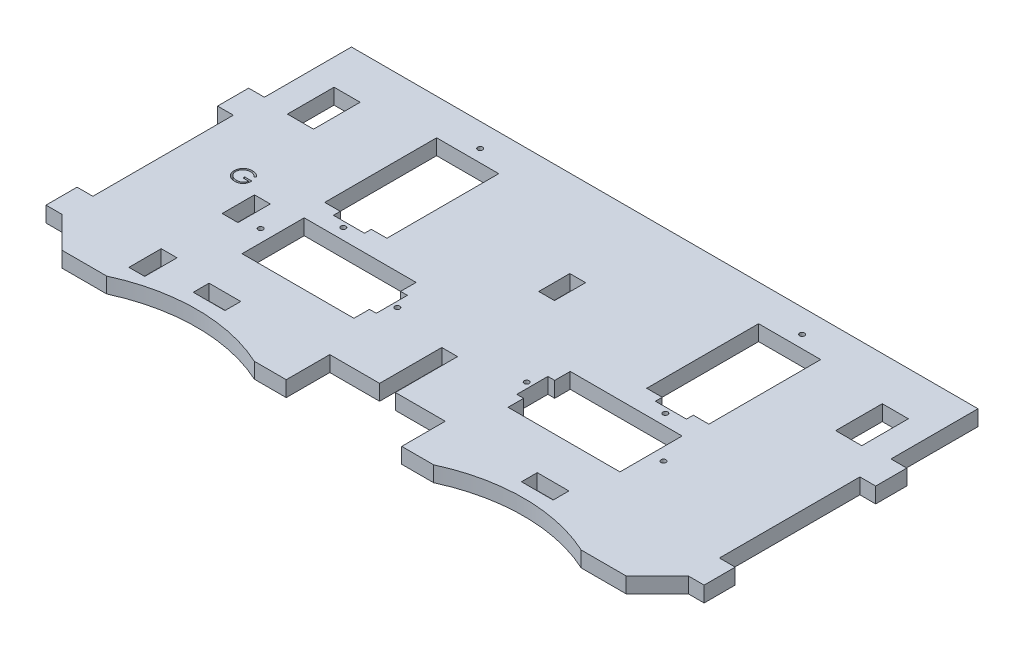
from build123d import *

# Parameters (mm, degrees)
SKETCH1_W                    = 128.016
SKETCH1_H                    = 60.452
MAIN_BODY_DEPTH              = 3.175
SKETCH2_W                    = 6.477
SKETCH2_H                    = 3.2258
CUT_FOR_EYE_CENTER_TAB_DEPTH = 71.857009286
SKETCH3_W                    = 3.2258
SKETCH3_H                    = 6.35
TABS_DEPTH                   = 3.175
SKETCH4_R                    = 0.508
CUT_FOR_MOTORS_DEPTH         = 74.783979043
SKETCH5_W                    = 3.2258
SKETCH5_H                    = 21.59
SKETCH5_H_2                  = 6.35
CUT_EXTRUDE2_DEPTH           = 74.783979043
CUT_EXTRUDE7_DEPTH           = 74.783979043
SKETCH10_W                   = 5.334
SKETCH10_H                   = 9.525
CUT_FOR_SERVO_WIRES_DEPTH    = 74.783979043
SKETCH12_W                   = 10.184723166
SKETCH12_H                   = 8.89
CUT_EXTRUDE9_DEPTH           = 74.783979043
SKETCH13_W                   = 128.016
SKETCH13_H                   = 5.08
BOSS_EXTRUDE1_DEPTH          = 3.175
SKETCH14_R                   = 0.508
CUT_EXTRUDE10_DEPTH          = 77.00643475
SKETCH15_W                   = 3.2258
SKETCH15_H                   = 6.604
CUT_FOR_GEAR_TABS_DEPTH      = 77.00643475
CUT_EXTRUDE11_DEPTH          = 77.00643475
CUT_EXTRUDE12_DEPTH          = 77.006434889


with BuildPart() as part:
    # Sketch1 → main body (new body)
    with BuildSketch(Plane(origin=(0, 0, 0), x_dir=(1, 0, 0), z_dir=(0, 1, 0))):
        Rectangle(SKETCH1_W, SKETCH1_H)
    extrude(amount=MAIN_BODY_DEPTH)

    # Sketch2 → cut for eye center tab (cut, through all)
    with BuildSketch(Plane(origin=(0, 3.175, 0), x_dir=(1, 0, 0), z_dir=(0, 1, 0))):
        with Locations((-33.528, -22.6441)):
            Rectangle(SKETCH2_W, SKETCH2_H)
    cut_for_eye_center_tab = extrude(amount=-CUT_FOR_EYE_CENTER_TAB_DEPTH, mode=Mode.SUBTRACT)

    # Sketch3 → tabs (add)
    with BuildSketch(Plane(origin=(0, 3.175, 0), x_dir=(1, 0, 0), z_dir=(0, 1, 0))):
        with Locations((-65.6209, -20.701)):
            Rectangle(SKETCH3_W, SKETCH3_H)
        with Locations((-65.6209, 14.351)):
            Rectangle(SKETCH3_W, SKETCH3_H)
    tabs = extrude(amount=-TABS_DEPTH)

    # Sketch4 → cut for motors (cut, through all)
    with BuildSketch(Plane(origin=(0, 3.175, 0), x_dir=(1, 0, 0), z_dir=(0, 1, 0))):
        with Locations((-32.893, 2.54)):
            Circle(SKETCH4_R)
        with Locations((-32.893, 30.48)):
            Circle(SKETCH4_R)
        with Locations((-13.208, -6.096)):
            Circle(SKETCH4_R)
        with Locations((-41.148, -6.096)):
            Circle(SKETCH4_R)
        Polygon((-26.543, 27.94), (-39.243, 27.94), (-39.243, 5.08), (-36.068, 5.08), (-36.068, 3.683), (-29.718, 3.683), (-29.718, 5.08), (-26.543, 5.08), align=None)
        Polygon((-38.608, 0.254), (-38.608, -12.446), (-15.748, -12.446), (-15.748, -9.271), (-14.351, -9.271), (-14.351, -2.921), (-15.748, -2.921), (-15.748, 0.254), align=None)
    cut_for_motors = extrude(amount=-CUT_FOR_MOTORS_DEPTH, mode=Mode.SUBTRACT)

    # Mirror of cut for motors: cut for motors across plane
    add(cut_for_motors.mirror(Plane(origin=(0, 0, 0), x_dir=(0, 0, 1), z_dir=(1, 0, 0))), mode=Mode.SUBTRACT)

    # mirror or tabs: tabs across plane
    add(tabs.mirror(Plane(origin=(0, 0, 0), x_dir=(0, 0, 1), z_dir=(1, 0, 0))))

    # mirror of eye center tab: cut for eye center tab across plane
    add(cut_for_eye_center_tab.mirror(Plane(origin=(0, 0, 0), x_dir=(0, 0, 1), z_dir=(1, 0, 0))), mode=Mode.SUBTRACT)

    # Sketch5 → Cut-Extrude2 (cut, through all)
    with BuildSketch(Plane(origin=(0, 3.175, 0), x_dir=(1, 0, 0), z_dir=(0, 1, 0))):
        with Locations((0, -19.431)):
            Rectangle(SKETCH5_W, SKETCH5_H)
        with Locations((0, 14.351)):
            Rectangle(SKETCH5_W, SKETCH5_H_2)
    extrude(amount=-CUT_EXTRUDE2_DEPTH, mode=Mode.SUBTRACT)

    # Sketch9 → Cut-Extrude7 (cut, through all)
    with BuildSketch(Plane(origin=(0, 3.175, 0), x_dir=(1, 0, 0), z_dir=(0, 1, 0))):
        Polygon((-64.008, -23.876), (-64.008, -30.226), (-57.658, -30.226), align=None)
        Polygon((64.008, -30.226), (64.008, -23.876), (57.658, -30.226), align=None)
    extrude(amount=-CUT_EXTRUDE7_DEPTH, mode=Mode.SUBTRACT)

    # Sketch10 → cut for servo wires (cut, through all)
    with BuildSketch(Plane(origin=(0, 3.175, 0), x_dir=(1, 0, 0), z_dir=(0, 1, 0))):
        with Locations((-56.007, 21.6535)):
            Rectangle(SKETCH10_W, SKETCH10_H)
    cut_for_servo_wires = extrude(amount=-CUT_FOR_SERVO_WIRES_DEPTH, mode=Mode.SUBTRACT)

    # Mirror1: cut for servo wires across plane
    add(cut_for_servo_wires.mirror(Plane(origin=(0, 0, 0), x_dir=(0, 0, 1), z_dir=(1, 0, 0))), mode=Mode.SUBTRACT)

    # Sketch12 → Cut-Extrude9 (cut, through all)
    with BuildSketch(Plane(origin=(0, 3.175, 0), x_dir=(1, 0, 0), z_dir=(0, 1, 0))):
        with Locations((-6.705261583, -25.781)):
            Rectangle(SKETCH12_W, SKETCH12_H)
    cut_extrude9 = extrude(amount=-CUT_EXTRUDE9_DEPTH, mode=Mode.SUBTRACT)

    # Mirror2: Cut-Extrude9 across plane
    add(cut_extrude9.mirror(Plane(origin=(0, 0, 0), x_dir=(0, 0, 1), z_dir=(1, 0, 0))), mode=Mode.SUBTRACT)

    # Sketch13 → Boss-Extrude1 (add)
    with BuildSketch(Plane(origin=(0, 3.175, 0), x_dir=(1, 0, 0), z_dir=(0, 1, 0))):
        with Locations((0, 32.766)):
            Rectangle(SKETCH13_W, SKETCH13_H)
    extrude(amount=-BOSS_EXTRUDE1_DEPTH)

    # Sketch14 → Cut-Extrude10 (cut, through all)
    with BuildSketch(Plane(origin=(0, 3.175, 0), x_dir=(1, 0, 0), z_dir=(0, 1, 0))):
        with Locations((-32.893, 30.48)):
            Circle(SKETCH14_R)
    cut_extrude10 = extrude(amount=-CUT_EXTRUDE10_DEPTH, mode=Mode.SUBTRACT)

    # Mirror3: Cut-Extrude10 across plane
    add(cut_extrude10.mirror(Plane(origin=(0, 0, 0), x_dir=(0, 0, 1), z_dir=(1, 0, 0))), mode=Mode.SUBTRACT)

    # Sketch15 → cut for gear tabs (cut, through all)
    with BuildSketch(Plane(origin=(0, 3.175, 0), x_dir=(1, 0, 0), z_dir=(0, 1, 0))):
        with Locations((-46.1391, -4.064)):
            Rectangle(SKETCH15_W, SKETCH15_H)
        with Locations((-46.1391, -23.114)):
            Rectangle(SKETCH15_W, SKETCH15_H)
    extrude(amount=-CUT_FOR_GEAR_TABS_DEPTH, mode=Mode.SUBTRACT)

    # Sketch16 → Cut-Extrude11 (cut, through all)
    with BuildSketch(Plane(origin=(0, 3.175, 0), x_dir=(1, 0, 0), z_dir=(0, 1, 0))):
        with BuildLine():
            Line((-50.659804407, 2.607078125), (-50.929035177, 2.351869792))
            add(Edge.make_bspline(
                [(-50.929035177, 2.351869792), (-50.977754065, 2.397700655), (-51.074030111, 2.488269518), (-51.230990354, 2.605780513), (-51.394753988, 2.706446613), (-51.564466485, 2.78835285), (-51.735925039, 2.85370561), (-51.906853815, 2.90023375), (-52.075499516, 2.929906288), (-52.187666735, 2.933454657), (-52.24293742, 2.935203125)],
                knots=[0, 0, 0, 0, 1.08915593, 2.152340314, 3.188132944, 4.216796309, 5.218260357, 6.173443236, 7.099959455, 8, 8, 8, 8], degree=3))
            add(Edge.make_bspline(
                [(-52.24293742, 2.935203125), (-52.27685212, 2.93478952), (-52.344593561, 2.93396338), (-52.445215505, 2.923419165), (-52.544782142, 2.908254301), (-52.643105517, 2.886312423), (-52.740376803, 2.858503364), (-52.836257695, 2.823717901), (-52.93092705, 2.783162656), (-53.023493131, 2.736300183), (-53.113233635, 2.684820336), (-53.19799047, 2.627771796), (-53.278303869, 2.566983006), (-53.352664294, 2.500932026), (-53.421499481, 2.430217161), (-53.486447853, 2.356153855), (-53.545225149, 2.276718636), (-53.598316314, 2.19337301), (-53.645677932, 2.107580821), (-53.687486586, 2.020167831), (-53.722583674, 1.931423977), (-53.750353129, 1.841237899), (-53.773263783, 1.750307309), (-53.78938139, 1.658002589), (-53.798468112, 1.564224904), (-53.800039892, 1.501427645), (-53.800830048, 1.469858574)],
                knots=[0, 0, 0, 0, 1.02818874, 2.053710826, 3.065248034, 4.081641283, 5.106893873, 6.131558223, 7.173050175, 8.228653731, 9.27666206, 10.308777013, 11.325269123, 12.329503258, 13.32196095, 14.316845687, 15.314881793, 16.315733098, 17.311955233, 18.285320748, 19.252783886, 20.203351036, 21.145449891, 22.095197417, 23.042428769, 24, 24, 24, 24], degree=3))
            add(Edge.make_bspline(
                [(-53.800830048, 1.469858574), (-53.80007433, 1.437587757), (-53.798564957, 1.373134243), (-53.788904638, 1.276940171), (-53.770976397, 1.182174768), (-53.747008688, 1.088526635), (-53.717027873, 0.995835387), (-53.679655207, 0.904502878), (-53.635389606, 0.814532486), (-53.584153054, 0.726734869), (-53.527966851, 0.641211846), (-53.46502377, 0.560652324), (-53.398163186, 0.483983547), (-53.324949286, 0.412907783), (-53.247729744, 0.345523887), (-53.164197468, 0.283688365), (-53.075995008, 0.226210142), (-52.982987796, 0.173813622), (-52.886185013, 0.127005087), (-52.78692826, 0.085381191), (-52.684900445, 0.051101853), (-52.580637755, 0.023163749), (-52.474264483, 0.000263452), (-52.365240681, -0.014469028), (-52.254367972, -0.025159859), (-52.17962934, -0.025941529), (-52.141975882, -0.026335336)],
                knots=[0, 0, 0, 0, 0.93586088, 1.869166235, 2.799637598, 3.729985548, 4.670839027, 5.622275134, 6.589130586, 7.576015415, 8.568469353, 9.55398029, 10.53834874, 11.515998671, 12.510579167, 13.508179873, 14.527009472, 15.561807829, 16.601455013, 17.643573243, 18.680854198, 19.719860599, 20.772568776, 21.833555941, 22.908541556, 24, 24, 24, 24], degree=3))
            add(Edge.make_bspline(
                [(-52.141975882, -0.026335336), (-52.096597535, -0.02538676), (-52.007489777, -0.023524076), (-51.876503335, -0.009023787), (-51.750700264, 0.013623007), (-51.630434061, 0.046788904), (-51.51556504, 0.089092579), (-51.405672099, 0.140087965), (-51.30162044, 0.201731024), (-51.203097266, 0.271304891), (-51.112340081, 0.348819724), (-51.030485957, 0.432464179), (-50.958840468, 0.521832246), (-50.896335768, 0.616397561), (-50.844627114, 0.716942866), (-50.802184319, 0.822975428), (-50.769651027, 0.93454294), (-50.756296052, 1.011634572), (-50.749547997, 1.050587741)],
                knots=[0, 0, 0, 0, 1.13008108, 2.219097802, 3.278683437, 4.311054135, 5.322181354, 6.324827112, 7.324222904, 8.330512327, 9.32562643, 10.293043162, 11.24128371, 12.174520618, 13.111833804, 14.052305215, 15.015860969, 16, 16, 16, 16], degree=3))
            Line((-50.749547997, 1.050587741), (-51.916214664, 1.050587741))
            Line((-51.916214664, 1.050587741), (-51.916214664, 1.4095621))
            Line((-51.916214664, 1.4095621), (-50.435445433, 1.4095621))
            add(Edge.make_bspline(
                [(-50.435445433, 1.4095621), (-50.437151281, 1.342654611), (-50.440489935, 1.211704569), (-50.463908851, 1.020734298), (-50.501725363, 0.840362605), (-50.553385675, 0.670399533), (-50.620260955, 0.511085941), (-50.701633483, 0.362260075), (-50.798805604, 0.224883394), (-50.908316046, 0.09783439), (-51.031216004, -0.015494822), (-51.164184624, -0.11510076), (-51.307441592, -0.199003375), (-51.4608514, -0.267264038), (-51.623911833, -0.320538033), (-51.797000213, -0.358309609), (-51.979881813, -0.380939573), (-52.10521849, -0.383830952), (-52.169319632, -0.385309695)],
                knots=[0, 0, 0, 0, 1.140356446, 2.231883559, 3.274166699, 4.278491846, 5.25512956, 6.21435461, 7.1637429, 8.11826594, 9.068280886, 10.0076534, 10.945064095, 11.891975133, 12.864533718, 13.863980011, 14.907571808, 16, 16, 16, 16], degree=3))
            add(Edge.make_bspline(
                [(-52.169319632, -0.385309695), (-52.208829767, -0.384740574), (-52.286756488, -0.383618083), (-52.401847416, -0.375640736), (-52.513765037, -0.36336016), (-52.622493046, -0.344815036), (-52.728431388, -0.322100382), (-52.831050973, -0.293013663), (-52.930742715, -0.259344964), (-53.0276607, -0.22104929), (-53.120925247, -0.176677634), (-53.210951764, -0.127367994), (-53.29823789, -0.073374633), (-53.382189055, -0.013763788), (-53.463242676, 0.051018672), (-53.54087612, 0.121102591), (-53.615523998, 0.196273711), (-53.662284461, 0.249652721), (-53.685846074, 0.276549279)],
                knots=[0, 0, 0, 0, 1.107784379, 2.184907829, 3.233506516, 4.263428166, 5.276301166, 6.270063455, 7.25232949, 8.225834625, 9.190232166, 10.146266622, 11.1027726, 12.066435141, 13.031522626, 14.010570082, 14.99756817, 16, 16, 16, 16], degree=3))
            add(Edge.make_bspline(
                [(-53.685846074, 0.276549279), (-53.720032006, 0.319219932), (-53.787836419, 0.403852949), (-53.875114575, 0.539452894), (-53.949515978, 0.679854754), (-54.0098838, 0.825449382), (-54.057021887, 0.976100595), (-54.090828139, 1.131615886), (-54.110635429, 1.292195517), (-54.113488966, 1.400860782), (-54.114932613, 1.455836138)],
                knots=[0, 0, 0, 0, 1.023165419, 2.029347347, 3.013907458, 3.994755782, 4.975994455, 5.96558838, 6.970761222, 8, 8, 8, 8], degree=3))
            add(Edge.make_bspline(
                [(-54.114932613, 1.455836138), (-54.114400374, 1.497002391), (-54.113342663, 1.578811698), (-54.100517146, 1.700269006), (-54.082115728, 1.819569698), (-54.055068674, 1.936616254), (-54.020972409, 2.051486846), (-53.978418923, 2.16423481), (-53.928874027, 2.274926682), (-53.871288531, 2.38280055), (-53.807204071, 2.486424962), (-53.737653851, 2.585382766), (-53.661650251, 2.677871831), (-53.580434451, 2.765063479), (-53.493037461, 2.845862326), (-53.400278038, 2.921016437), (-53.302084695, 2.990626622), (-53.198148515, 3.053596457), (-53.09002083, 3.110160078), (-52.977960829, 3.159749289), (-52.862002718, 3.200732605), (-52.74301524, 3.235506384), (-52.62009774, 3.261221525), (-52.494142203, 3.27987027), (-52.364492091, 3.29263087), (-52.276856061, 3.293657126), (-52.232420593, 3.294177484)],
                knots=[0, 0, 0, 0, 1.008945113, 2.00506715, 2.99143336, 3.967273523, 4.948097931, 5.927297278, 6.919902385, 7.919676788, 8.923139349, 9.905703106, 10.883022732, 11.856032218, 12.825136022, 13.798837087, 14.781400844, 15.773989409, 16.776158564, 17.77167057, 18.775803737, 19.789618931, 20.80898985, 21.851988756, 22.910860228, 24, 24, 24, 24], degree=3))
            add(Edge.make_bspline(
                [(-52.232420593, 3.294177484), (-52.19618235, 3.293597993), (-52.124326171, 3.292448929), (-52.017400439, 3.284484281), (-51.912127424, 3.271860399), (-51.808351034, 3.254633613), (-51.706424668, 3.231169922), (-51.606057962, 3.203091638), (-51.507105426, 3.170399815), (-51.409877177, 3.131410969), (-51.313719461, 3.087157344), (-51.218097621, 3.037343921), (-51.123338375, 2.981118917), (-51.029277393, 2.918315381), (-50.935321535, 2.850011963), (-50.842956893, 2.77425514), (-50.749953949, 2.694032384), (-50.690152134, 2.6363502), (-50.659804407, 2.607078125)],
                knots=[0, 0, 0, 0, 0.985871117, 1.954866573, 2.915460327, 3.869826059, 4.81536089, 5.759505086, 6.70452669, 7.649098992, 8.607881297, 9.583363685, 10.581137262, 11.603961102, 12.659522466, 13.73993555, 14.853081303, 16, 16, 16, 16], degree=3))
        make_face()
    extrude(amount=-CUT_EXTRUDE11_DEPTH, mode=Mode.SUBTRACT)

    # Sketch17 → Cut-Extrude12 (cut, through all)
    with BuildSketch(Plane(origin=(0, 3.175, 0), x_dir=(1, 0, 0), z_dir=(0, 1, 0))):
        with BuildLine():
            Line((-48.473874948, -30.226), (-18.32273799, -30.226))
            ThreePointArc((-18.32273799, -30.226), (-33.398306469, -26.916581722), (-48.473874948, -30.226))
        make_face()
    cut_extrude12 = extrude(amount=-CUT_EXTRUDE12_DEPTH, mode=Mode.SUBTRACT)

    # Mirror4: Cut-Extrude12 across Right Plane
    add(cut_extrude12.mirror(Plane(origin=(0, 0, 0), x_dir=(0, 0, -1), z_dir=(1, 0, 0))), mode=Mode.SUBTRACT)


solid = part.part
